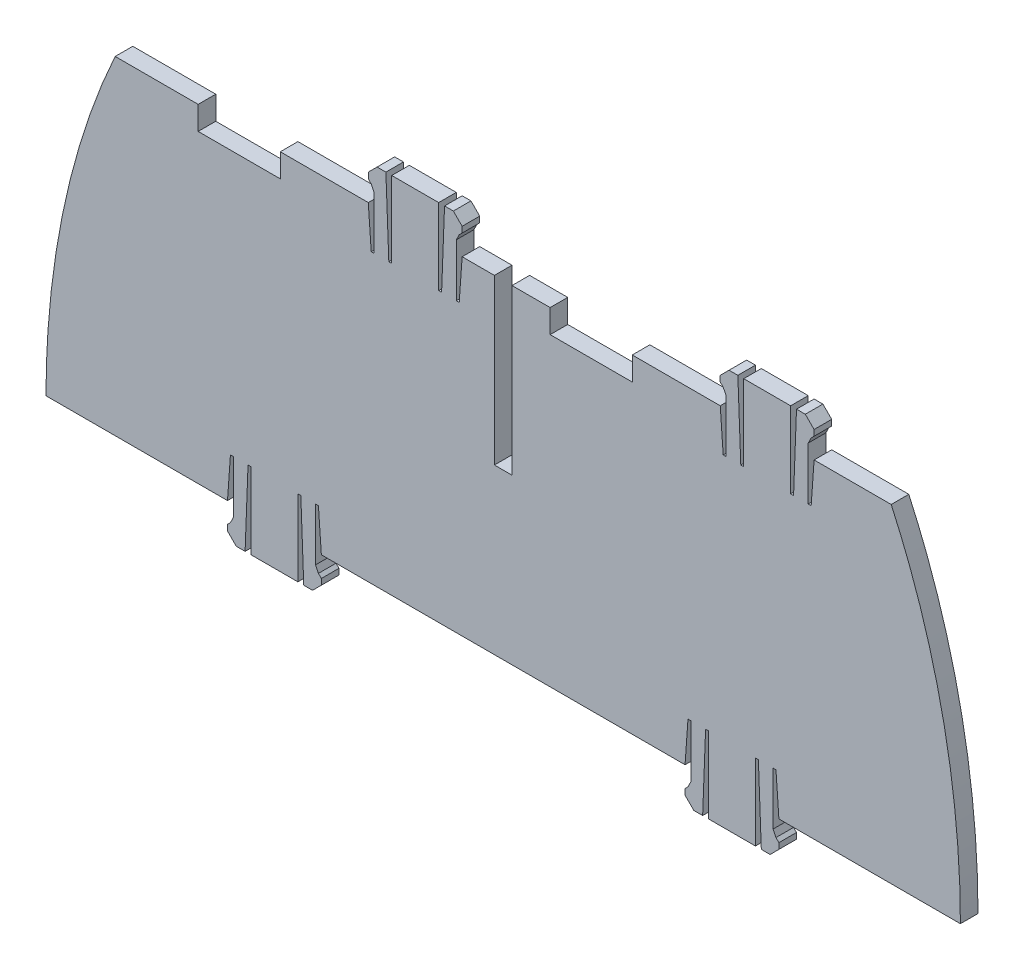
from build123d import *

# Parameters (mm, degrees)
BOSS_EXTRUDE1_DEPTH     = 3
SKETCH9_W               = 14
SKETCH9_H               = 4
CUT_EXTRUDE3_DEPTH      = 4.0000001
CUT_EXTRUDE4_DEPTH      = 1.0000001
CUT_EXTRUDE4_DEPTH_BACK = 3


with BuildPart() as part:
    # Sketch1 → Boss-Extrude1 (new body)
    with BuildSketch(Plane.XY):
        with BuildLine():
            Line((-39, 0), (-8, 0))
            Line((-8, 0), (-7.5, 7.002171092))
            Line((-7.5, 7.002171092), (-7, 7.002171092))
            Line((-7, 7.002171092), (-7, -1.997828908))
            Line((-7, -1.997828908), (-7.5, -2.997828908))
            Line((-7.5, -2.997828908), (-8, -3.497828908))
            Line((-8, -3.497828908), (-8, -4.497828908))
            Line((-8, -4.497828908), (-6.5, -5.997828908))
            Line((-6.5, -5.997828908), (-5, -5.997828908))
            Line((-5, -5.997828908), (-4.5, 7.002171092))
            Line((-4.5, 7.002171092), (-4, 7.002171092))
            Line((-4, 7.002171092), (-4, -5.997828908))
            Line((-4, -5.997828908), (4, -5.997828908))
            Line((4, -5.997828908), (4, 7.002171092))
            Line((4, 7.002171092), (4.5, 7.002171092))
            Line((4.5, 7.002171092), (5, -5.997828908))
            Line((5, -5.997828908), (6.5, -5.997828908))
            Line((6.5, -5.997828908), (8, -4.497828908))
            Line((8, -4.497828908), (8, -3.497828908))
            Line((8, -3.497828908), (7.5, -2.997828908))
            Line((7.5, -2.997828908), (7, -1.997828908))
            Line((7, -1.997828908), (7, 7.002171092))
            Line((7, 7.002171092), (7.5, 7.002171092))
            Line((7.5, 7.002171092), (8, 0))
            Line((8, 0), (38.94, 0))
            add(Edge.make_bspline(
                [(38.94, 0), (38.94, 30.292119235), (27.145, 56)],
                knots=[1.570796327, 1.570796327, 1.570796327, 2.128135243, 2.128135243, 2.128135243], degree=2, weights=[1, 0.96142229, 1]))
            Line((27.145, 56), (14, 56))
            Line((14, 56), (13.5, 48.997828908))
            Line((13.5, 48.997828908), (13, 48.997828908))
            Line((13, 48.997828908), (13, 57.997828908))
            Line((13, 57.997828908), (13.5, 58.997828908))
            Line((13.5, 58.997828908), (14, 59.497828908))
            Line((14, 59.497828908), (14, 60.497828908))
            Line((14, 60.497828908), (12.5, 61.997828908))
            Line((12.5, 61.997828908), (11, 61.997828908))
            Line((11, 61.997828908), (10.5, 48.997828908))
            Line((10.5, 48.997828908), (10, 48.997828908))
            Line((10, 48.997828908), (10, 61.997828908))
            Line((10, 61.997828908), (2, 61.997828908))
            Line((2, 61.997828908), (2, 48.997828908))
            Line((2, 48.997828908), (1.5, 48.997828908))
            Line((1.5, 48.997828908), (1, 61.997828908))
            Line((1, 61.997828908), (-0.5, 61.997828908))
            Line((-0.5, 61.997828908), (-2, 60.497828908))
            Line((-2, 60.497828908), (-2, 59.497828908))
            Line((-2, 59.497828908), (-1.5, 58.997828908))
            Line((-1.5, 58.997828908), (-1, 57.997828908))
            Line((-1, 57.997828908), (-1, 48.997828908))
            Line((-1, 48.997828908), (-1.5, 48.997828908))
            Line((-1.5, 48.997828908), (-2, 56))
            Line((-2, 56), (-46, 56))
            Line((-46, 56), (-46.5, 48.997828908))
            Line((-46.5, 48.997828908), (-47, 48.997828908))
            Line((-47, 48.997828908), (-47, 57.997828908))
            Line((-47, 57.997828908), (-46.5, 58.997828908))
            Line((-46.5, 58.997828908), (-46, 59.497828908))
            Line((-46, 59.497828908), (-46, 60.497828908))
            Line((-46, 60.497828908), (-47.5, 61.997828908))
            Line((-47.5, 61.997828908), (-49, 61.997828908))
            Line((-49, 61.997828908), (-49.5, 48.997828908))
            Line((-49.5, 48.997828908), (-50, 48.997828908))
            Line((-50, 48.997828908), (-50, 61.997828908))
            Line((-50, 61.997828908), (-58, 61.997828908))
            Line((-58, 61.997828908), (-58, 48.997828908))
            Line((-58, 48.997828908), (-58.5, 48.997828908))
            Line((-58.5, 48.997828908), (-59, 61.997828908))
            Line((-59, 61.997828908), (-60.5, 61.997828908))
            Line((-60.5, 61.997828908), (-62, 60.497828908))
            Line((-62, 60.497828908), (-62, 59.497828908))
            Line((-62, 59.497828908), (-61.5, 58.997828908))
            Line((-61.5, 58.997828908), (-61, 57.997828908))
            Line((-61, 57.997828908), (-61, 48.997828908))
            Line((-61, 48.997828908), (-61.5, 48.997828908))
            Line((-61.5, 48.997828908), (-62, 56))
            Line((-62, 56), (-105.145, 56))
            add(Edge.make_bspline(
                [(-105.145, 56), (-116.94, 30.292119235), (-116.94, 0)],
                knots=[4.155050064, 4.155050064, 4.155050064, 4.71238898, 4.71238898, 4.71238898], degree=2, weights=[1, 0.96142229, 1]))
            Line((-116.94, 0), (-86, 0))
            Line((-86, 0), (-85.5, 7.002171092))
            Line((-85.5, 7.002171092), (-85, 7.002171092))
            Line((-85, 7.002171092), (-85, -1.997828908))
            Line((-85, -1.997828908), (-85.5, -2.997828908))
            Line((-85.5, -2.997828908), (-86, -3.497828908))
            Line((-86, -3.497828908), (-86, -4.497828908))
            Line((-86, -4.497828908), (-84.5, -5.997828908))
            Line((-84.5, -5.997828908), (-83, -5.997828908))
            Line((-83, -5.997828908), (-82.5, 7.002171092))
            Line((-82.5, 7.002171092), (-82, 7.002171092))
            Line((-82, 7.002171092), (-82, -5.997828908))
            Line((-82, -5.997828908), (-74, -5.997828908))
            Line((-74, -5.997828908), (-74, 7.002171092))
            Line((-74, 7.002171092), (-73.5, 7.002171092))
            Line((-73.5, 7.002171092), (-73, -5.997828908))
            Line((-73, -5.997828908), (-71.5, -5.997828908))
            Line((-71.5, -5.997828908), (-70, -4.497828908))
            Line((-70, -4.497828908), (-70, -3.497828908))
            Line((-70, -3.497828908), (-70.5, -2.997828908))
            Line((-70.5, -2.997828908), (-71, -1.997828908))
            Line((-71, -1.997828908), (-71, 7.002171092))
            Line((-71, 7.002171092), (-70.5, 7.002171092))
            Line((-70.5, 7.002171092), (-70, 0))
            Line((-70, 0), (-39, 0))
        make_face()
    extrude(amount=BOSS_EXTRUDE1_DEPTH)

    # Sketch9 → Cut-Extrude3 (cut, through all)
    with BuildSketch(Plane.XY.offset(3)):
        with Locations((-24, 54)):
            Rectangle(SKETCH9_W, SKETCH9_H)
        with Locations((-84, 54)):
            Rectangle(SKETCH9_W, SKETCH9_H)
    extrude(amount=-CUT_EXTRUDE3_DEPTH, mode=Mode.SUBTRACT)

    # Sketch11 → Cut-Extrude4 (cut, two sides)
    with BuildSketch(Plane.XY.offset(3)) as cut_extrude4_sk:
        Polygon((-40.5, 267.538526516), (-40.5, 56), (-40.5, 28), (-37.5, 28), (-37.5, 56), (-37.5, 267.538526516), (-37.5, 690.615579549), (-40.5, 690.615579549), align=None)
    extrude(amount=CUT_EXTRUDE4_DEPTH, mode=Mode.SUBTRACT)
    extrude(cut_extrude4_sk.sketch, amount=-CUT_EXTRUDE4_DEPTH_BACK, mode=Mode.SUBTRACT)


solid = part.part
